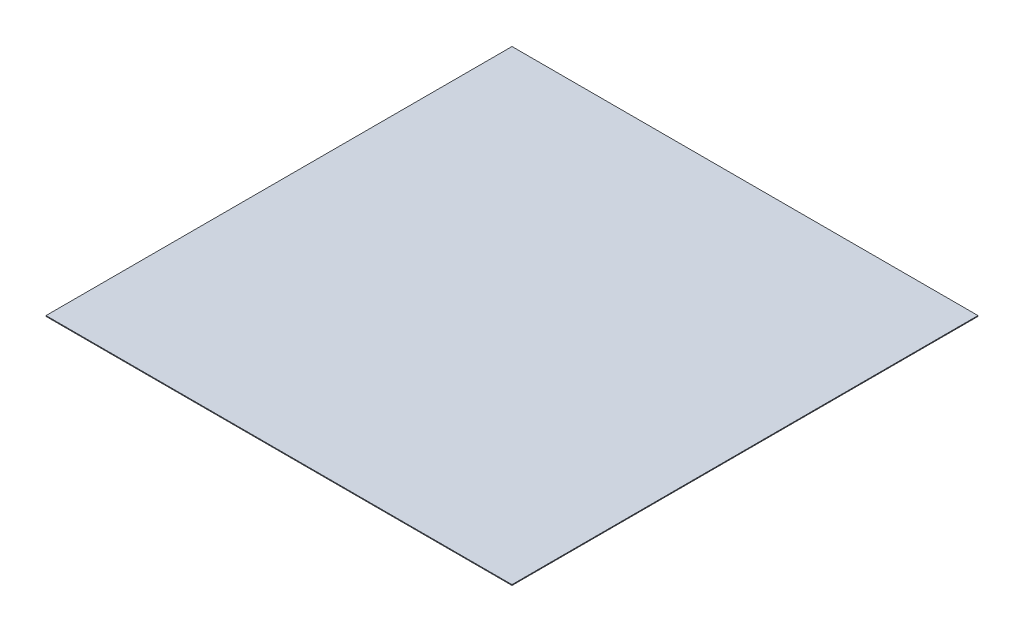
from build123d import *

# Parameters (mm, degrees)
SKETCH1_W           = 762
SKETCH1_H           = 762
BOSS_EXTRUDE1_DEPTH = 1.27


with BuildPart() as part:
    # Sketch1 → Boss-Extrude1 (new body)
    with BuildSketch(Plane(origin=(0, 0, 0), x_dir=(1, 0, 0), z_dir=(0, 1, 0))):
        Rectangle(SKETCH1_W, SKETCH1_H)
    extrude(amount=BOSS_EXTRUDE1_DEPTH)


solid = part.part
